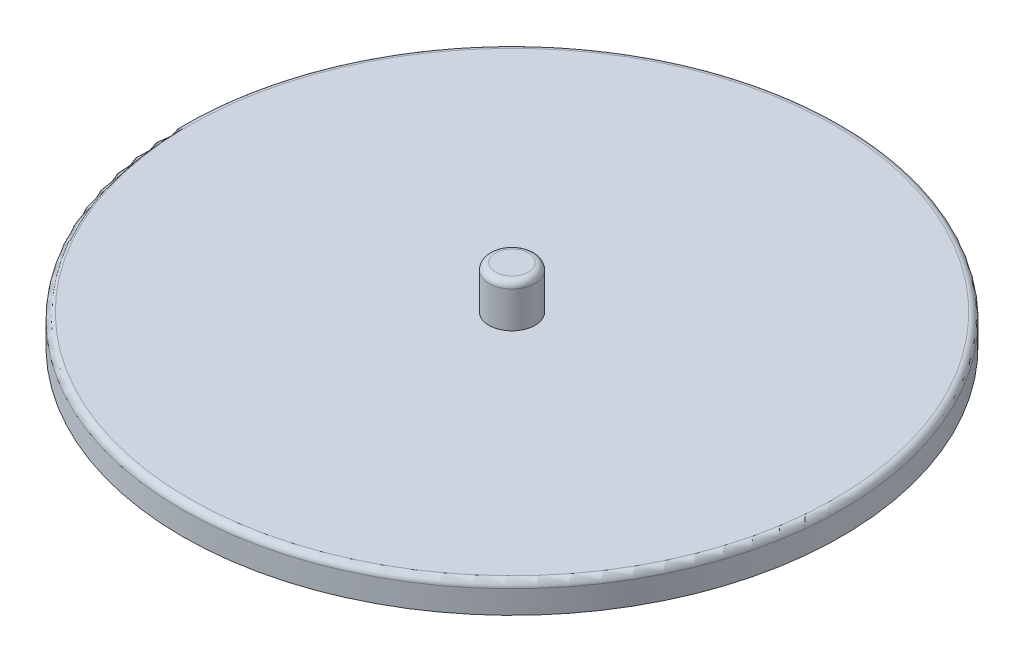
from build123d import *

# Parameters (mm, degrees)
SKETCH1_R           = 100
BOSS_EXTRUDE1_DEPTH = 9
SKETCH2_R           = 7
BOSS_EXTRUDE2_DEPTH = 13
FILLET1_R           = 2


with BuildPart() as part:
    # Sketch1 → Boss-Extrude1 (new body)
    with BuildSketch(Plane(origin=(0, 0, 0), x_dir=(1, 0, 0), z_dir=(0, 1, 0))):
        Circle(SKETCH1_R)
    extrude(amount=BOSS_EXTRUDE1_DEPTH)

    # Sketch2 → Boss-Extrude2 (add)
    with BuildSketch(Plane(origin=(0, 9, 0), x_dir=(1, 0, 0), z_dir=(0, 1, 0))):
        Circle(SKETCH2_R)
    extrude(amount=BOSS_EXTRUDE2_DEPTH)

    # Fillet1
    fillet1_edges = [part.edges().sort_by_distance(p)[0] for p in [
        (-100, 9, 0),
        (-7, 22, 0),
    ]]
    fillet(fillet1_edges, radius=FILLET1_R)


solid = part.part
